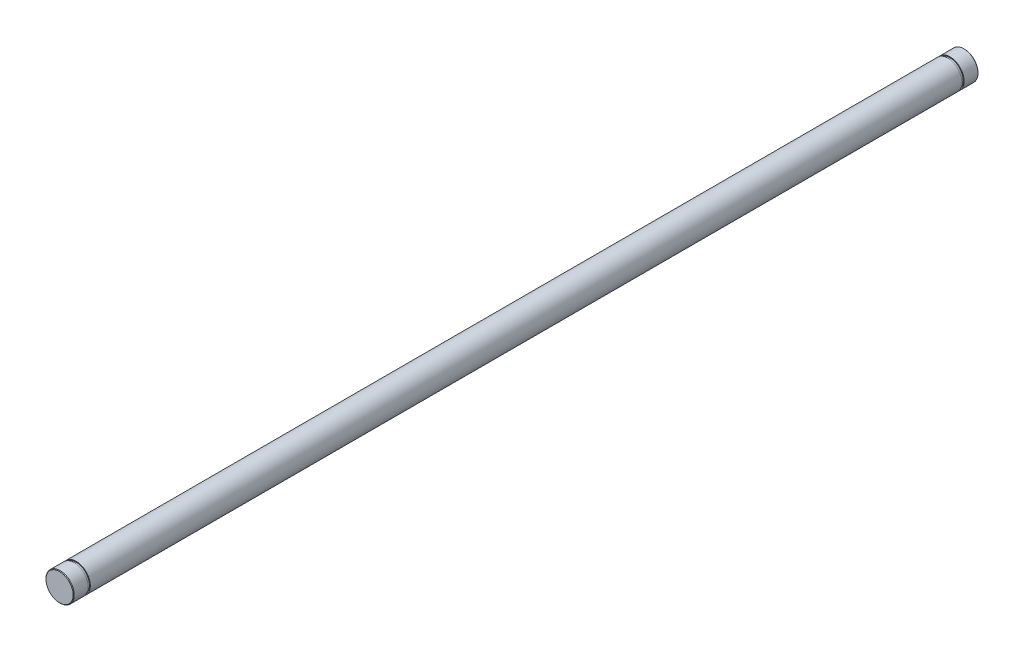
from build123d import *

# Parameters (mm, degrees)
SKETCH3_R                = 4.7625
BOSS_EXTRUDE1_DEPTH      = 152.4
BOSS_EXTRUDE1_DEPTH_BACK = 152.4
CHAMFER1_SIZE            = 0.1905
SKETCH4_W                = 0.2921
SKETCH4_H                = 0.7366


with BuildPart() as part:
    # Sketch3 → Boss-Extrude1 (new body, two sides)
    with BuildSketch(Plane.XY) as boss_extrude1_sk:
        Circle(SKETCH3_R)
    extrude(amount=BOSS_EXTRUDE1_DEPTH)
    extrude(boss_extrude1_sk.sketch, amount=-BOSS_EXTRUDE1_DEPTH_BACK)

    # Chamfer1
    chamfer1_edges = [part.edges().sort_by_distance(p)[0] for p in [
        (-4.7625, 0, -152.4),
        (-4.7625, 0, 152.4),
    ]]
    chamfer(chamfer1_edges, length=CHAMFER1_SIZE)

    # Sketch4 → Cut-Revolve1 (revolve, cut)
    with BuildSketch(Plane(origin=(0, 0, 0), x_dir=(1, 0, 0), z_dir=(0, 1, 0))):
        with Locations((4.61645, 147.1683)):
            Rectangle(SKETCH4_W, SKETCH4_H)
        with Locations((4.61645, -147.1683)):
            Rectangle(SKETCH4_W, SKETCH4_H)
    revolve(axis=Axis((0, 0, 1000), (0, 0, -1)), mode=Mode.SUBTRACT)


solid = part.part
